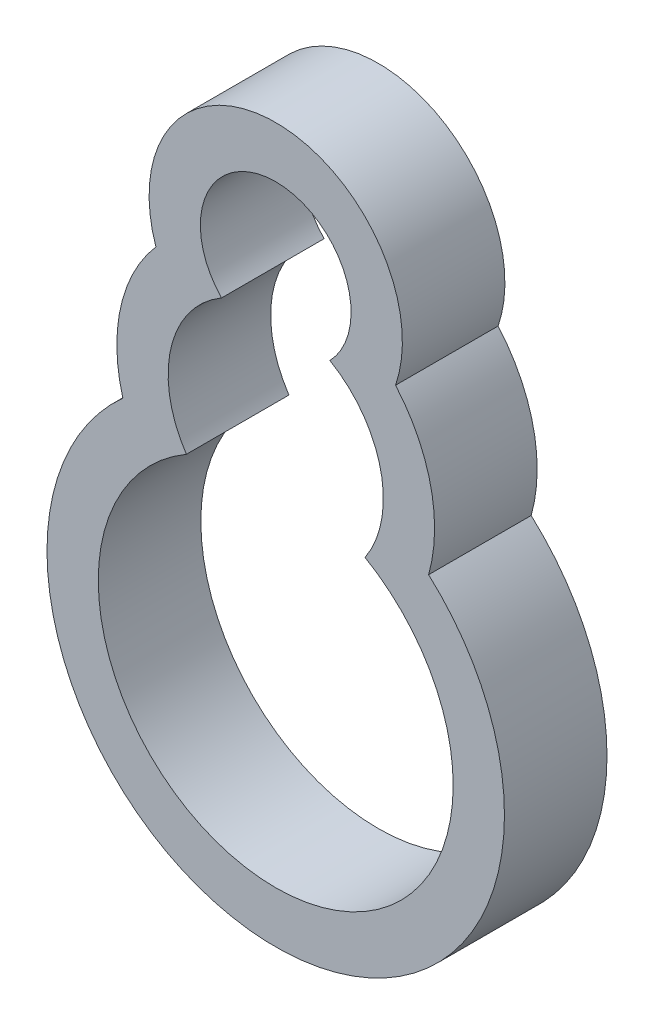
from build123d import *

# Parameters (mm, degrees)
BOSS_EXTRUDE1_DEPTH = 10


with BuildPart() as part:
    # Sketch1 → Boss-Extrude1 (new body)
    with BuildSketch(Plane.XY):
        with BuildLine():
            ThreePointArc((11.683930306, 19.194983415), (0, 35.545065903), (-11.683930306, 19.194983415))
            ThreePointArc((-11.683930306, 19.194983415), (-15.117887521, 12.409490467), (-14.909304212, 4.807420374))
            ThreePointArc((-14.909304212, 4.807420374), (0, -34.086168219), (14.909304212, 4.807420374))
            ThreePointArc((14.909304212, 4.807420374), (15.117887521, 12.409490467), (11.683930306, 19.194983415))
        make_face()
        with BuildLine():
            ThreePointArc((5.283589413, 18.086212607), (0, 30.545065903), (-5.283589413, 18.086212607))
            ThreePointArc((-5.283589413, 18.086212607), (-10.226606654, 11.370266597), (-8.710983133, 3.170252232))
            ThreePointArc((-8.710983133, 3.170252232), (0, -29.086168219), (8.710983133, 3.170252232))
            ThreePointArc((8.710983133, 3.170252232), (10.226606654, 11.370266597), (5.283589413, 18.086212607))
        make_face(mode=Mode.SUBTRACT)
    extrude(amount=BOSS_EXTRUDE1_DEPTH)


solid = part.part
